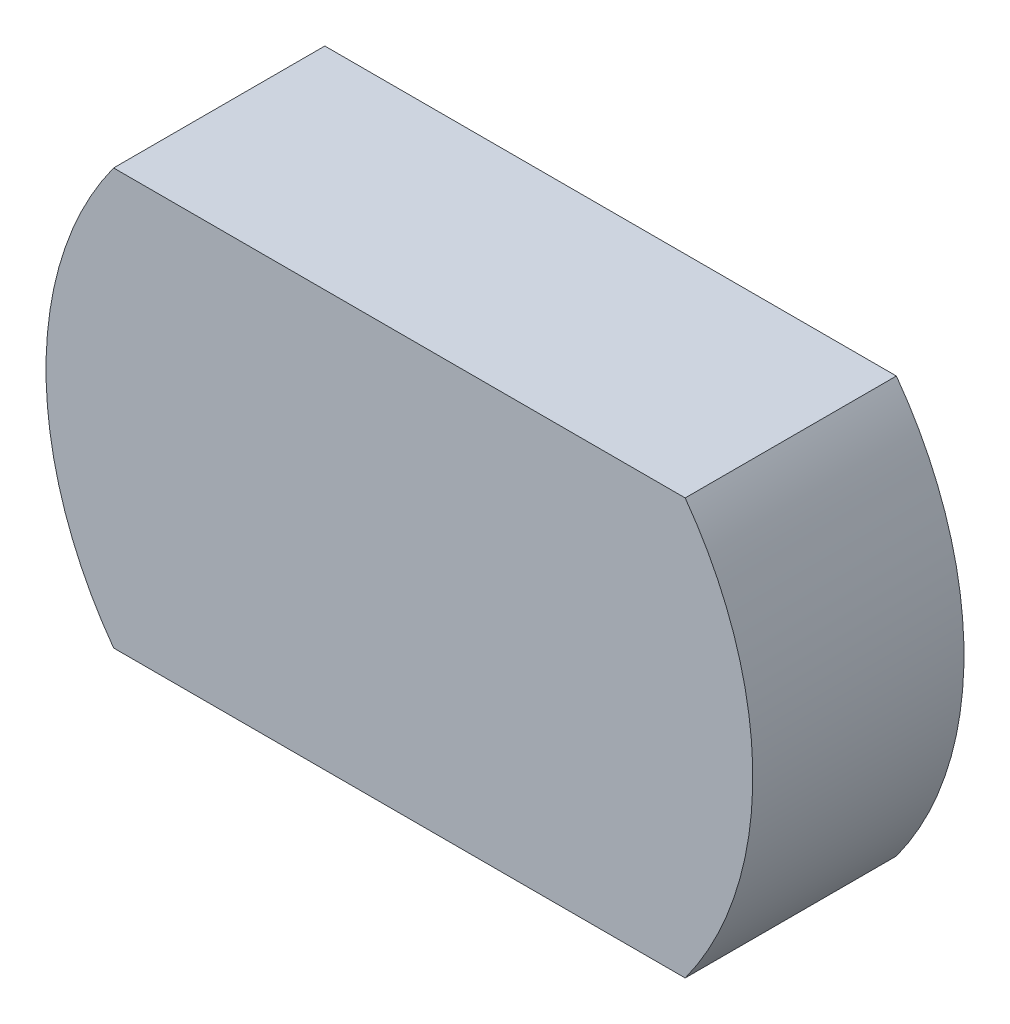
from build123d import *

# Parameters (mm, degrees)
BOSS_EXTRUDE2_DEPTH = 25.4


with BuildPart() as part:
    # Sketch5 → Boss-Extrude2 (new body)
    with BuildSketch(Plane.XY):
        with BuildLine():
            Line((-34.369317712, 25), (34.369317712, 25))
            ThreePointArc((34.369317712, 25), (42.5, 0), (34.369317712, -25))
            Line((34.369317712, -25), (-34.369317712, -25))
            ThreePointArc((-34.369317712, -25), (-42.5, 0), (-34.369317712, 25))
        make_face()
    extrude(amount=BOSS_EXTRUDE2_DEPTH)


solid = part.part
